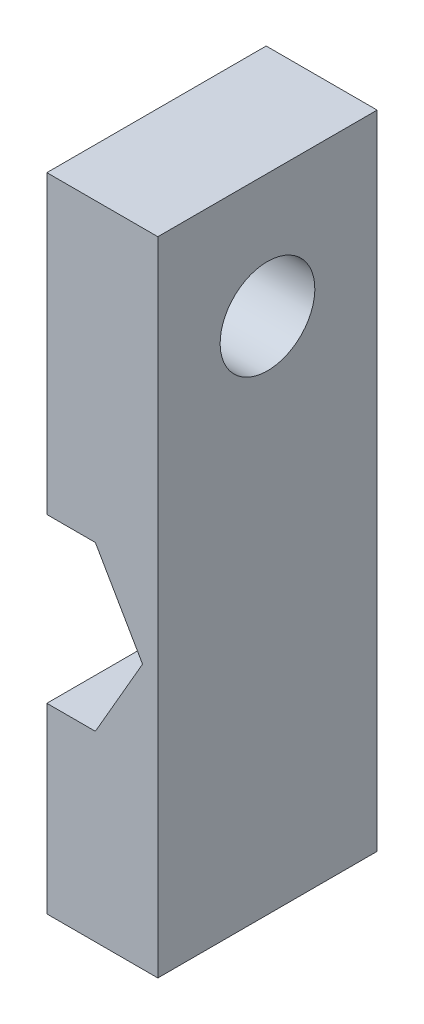
from build123d import *

# Parameters (mm, degrees)
SKETCH_1_W          = 22
SKETCH_1_H          = 64.4
EXTRUDE_1_DEPTH     = 22
SKETCH_2_R          = 4.75
CUT_EXTRUDE_1_DEPTH = 22
SKETCH_3_W          = 22
SKETCH_3_H          = 64.4
CUT_EXTRUDE_2_DEPTH = 11


with BuildPart() as part:
    # 草圖1 → 填料-伸長1 (new body)
    with BuildSketch(Plane.XY):
        with Locations((0.13253012, -27.579314659)):
            Rectangle(SKETCH_1_W, SKETCH_1_H)
        Polygon((9.601074535, -33.279314659), (4.866802328, -25.079314659), (-4.601742087, -25.079314659), (-9.336014294, -33.279314659), (-4.601742087, -41.479314659), (4.866802328, -41.479314659), align=None, mode=Mode.SUBTRACT)
    extrude(amount=EXTRUDE_1_DEPTH)

    # 草圖2 → 除料-伸長1 (cut)
    with BuildSketch(Plane(origin=(11.13253012, 0, 0), x_dir=(0, 0, -1), z_dir=(1, 0, 0))):
        with Locations((-11, -7.779314659)):
            Circle(SKETCH_2_R)
    extrude(amount=-CUT_EXTRUDE_1_DEPTH, mode=Mode.SUBTRACT)

    # 草圖3 → 除料-伸長2 (cut)
    with BuildSketch(Plane(origin=(0, 0, 0), x_dir=(0, 0, -1), z_dir=(1, 0, 0))):
        with Locations((-11, -27.579314659)):
            Rectangle(SKETCH_3_W, SKETCH_3_H)
    extrude(amount=-CUT_EXTRUDE_2_DEPTH, mode=Mode.SUBTRACT)


solid = part.part
